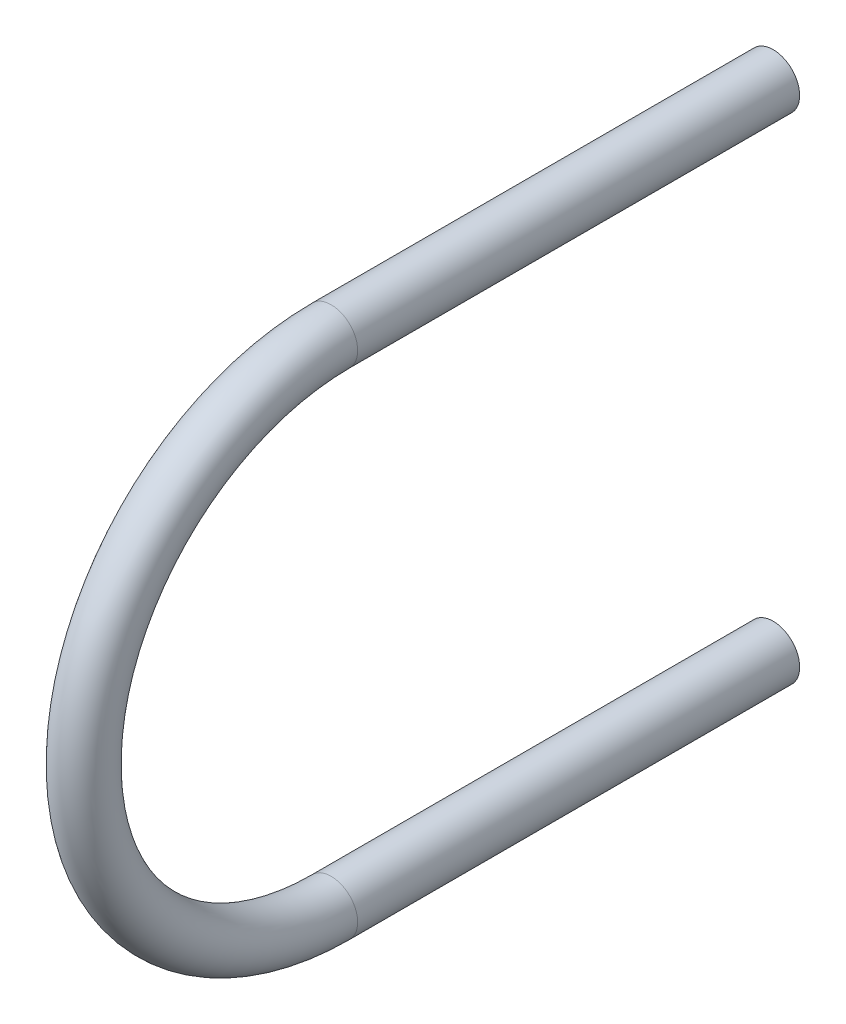
from build123d import *

# Parameters (mm, degrees)
SWEEP_1_PROFILE_R = 3


with BuildPart() as part:
    # По траектории1: sweep along a path in Эскиз1
    with BuildLine(Plane(origin=(0, 0, 0), x_dir=(0, 0, -1), z_dir=(1, 0, 0))) as sweep_1_path:
        Line((50, 56), (0, 56))
        ThreePointArc((0, 56), (-28, 28), (0, 0))
        Line((0, 0), (50, 0))
    # По траектории1 profile (on start of the path) → По траектории1 (sweep)
    with BuildSketch(Plane(origin=(0, 56, -50), x_dir=(1, 0, 0), z_dir=(0, 0, 1))):
        Circle(SWEEP_1_PROFILE_R)
    sweep(path=sweep_1_path.line)


solid = part.part
